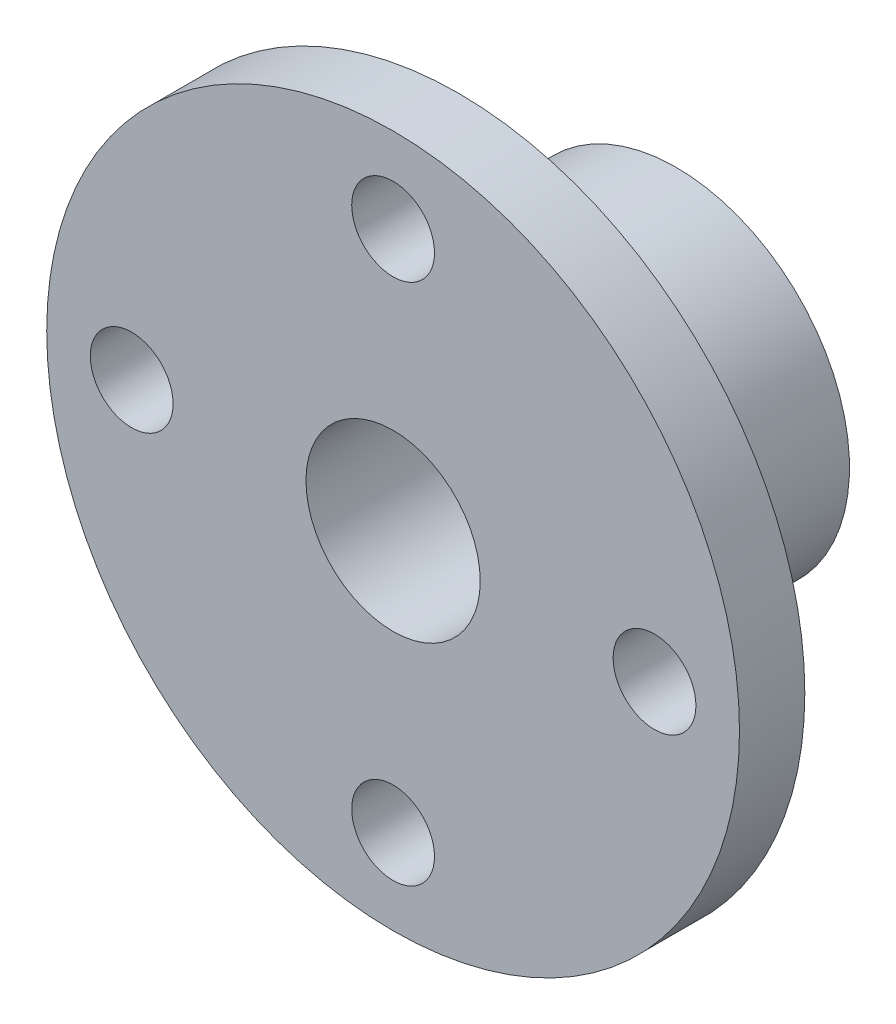
from build123d import *

# Parameters (mm, degrees)
SKETCH1_R           = 15.9
BOSS_EXTRUDE1_DEPTH = 3
SKETCH2_R           = 7.95
BOSS_EXTRUDE2_DEPTH = 10
SKETCH3_R           = 4
CUT_EXTRUDE1_DEPTH  = 20
SKETCH4_R           = 1.9
CUT_EXTRUDE2_DEPTH  = 20


with BuildPart() as part:
    # Sketch1 → Boss-Extrude1 (new body)
    with BuildSketch(Plane.XY):
        Circle(SKETCH1_R)
    extrude(amount=BOSS_EXTRUDE1_DEPTH)

    # Sketch2 → Boss-Extrude2 (add)
    with BuildSketch(Plane(origin=(0, 0, 0), x_dir=(-1, 0, 0), z_dir=(0, 0, -1))):
        Circle(SKETCH2_R)
    extrude(amount=BOSS_EXTRUDE2_DEPTH)

    # Sketch3 → Cut-Extrude1 (cut)
    with BuildSketch(Plane(origin=(0, 0, -10), x_dir=(-1, 0, 0), z_dir=(0, 0, -1))):
        Circle(SKETCH3_R)
    extrude(amount=-CUT_EXTRUDE1_DEPTH, mode=Mode.SUBTRACT)

    # Sketch4 → Cut-Extrude2 (cut)
    with BuildSketch(Plane(origin=(0, 0, 0), x_dir=(-1, 0, 0), z_dir=(0, 0, -1))):
        with Locations((0, 12)):
            Circle(SKETCH4_R)
        with Locations((-12, 0)):
            Circle(SKETCH4_R)
        with Locations((12, 0)):
            Circle(SKETCH4_R)
        with Locations((0, -12)):
            Circle(SKETCH4_R)
    extrude(amount=-CUT_EXTRUDE2_DEPTH, mode=Mode.SUBTRACT)


solid = part.part
